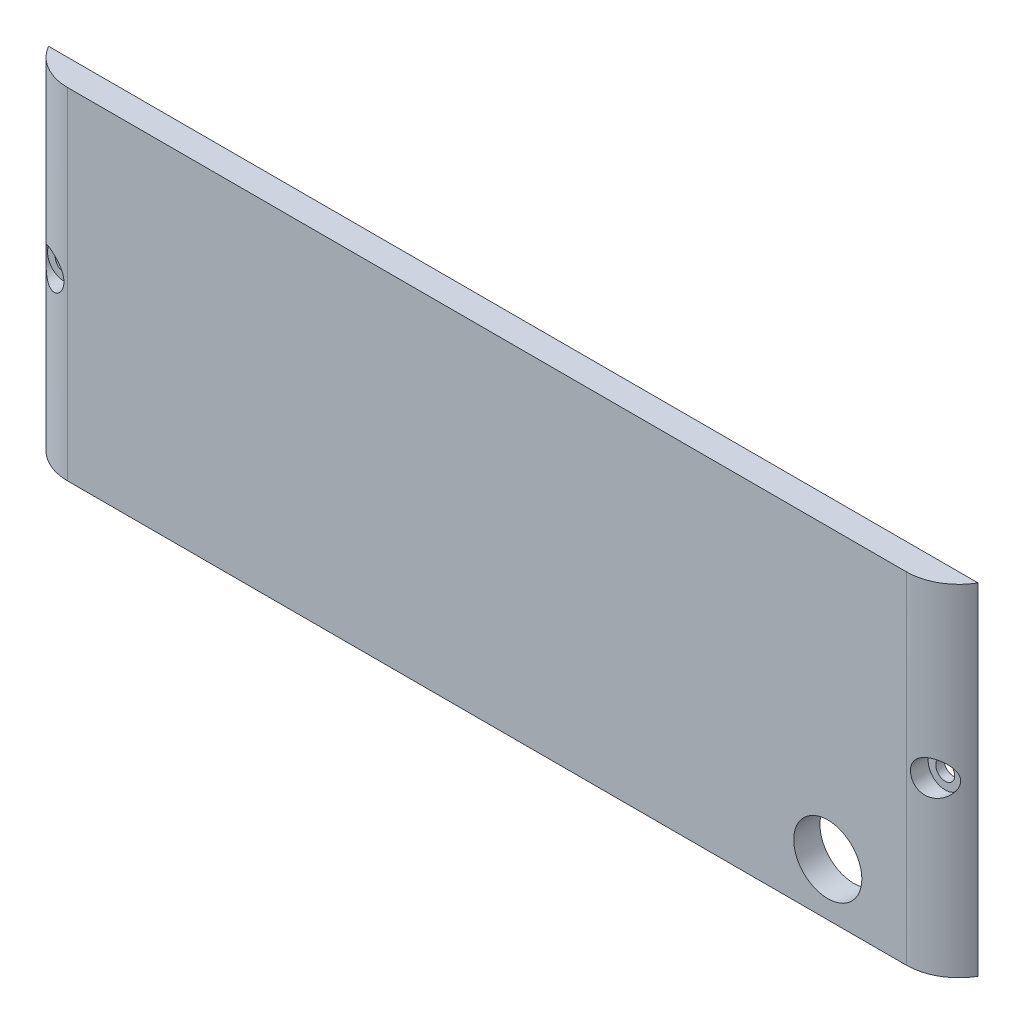
from build123d import *

# Parameters (mm, degrees)
SKIZZE1_W                                            = 180
SKIZZE1_H                                            = 65
AUFSATZ_LINEAR_AUSTRAGEN1_DEPTH                      = 5
STIRNSENKUNG_F_R_M3_ZYLINDERSCHRAUBE_MIT_D           = 3.6
STIRNSENKUNG_F_R_M3_ZYLINDERSCHRAUBE_MIT_DEPTH       = 9.1
STIRNSENKUNG_F_R_M3_ZYLINDERSCHRAUBE_MIT_CBORE_D     = 6.5
STIRNSENKUNG_F_R_M3_ZYLINDERSCHRAUBE_MIT_CBORE_DEPTH = 3.4
STIRNSENKUNG_F_R_M3_ZYLINDERSCHRAUBE_MIT_TIP         = 1.081549114
SCHNITT_LINEAR_AUSTRAGEN1_DEPTH                      = 66
SKIZZE7_R                                            = 6.5
SCHNITT_LINEAR_AUSTRAGEN2_DEPTH                      = 6.0000001


with BuildPart() as part:
    # Skizze1 → Aufsatz-Linear austragen1 (new body)
    with BuildSketch(Plane.XY):
        Rectangle(SKIZZE1_W, SKIZZE1_H)
    extrude(amount=AUFSATZ_LINEAR_AUSTRAGEN1_DEPTH)

    # Stirnsenkung für M3 Zylinderschraube mit Innensechskant1
    with Locations(Plane.XY.offset(5)):
        with Locations((-84, 0), (84, 0)):
            CounterBoreHole(STIRNSENKUNG_F_R_M3_ZYLINDERSCHRAUBE_MIT_D / 2, STIRNSENKUNG_F_R_M3_ZYLINDERSCHRAUBE_MIT_CBORE_D / 2, STIRNSENKUNG_F_R_M3_ZYLINDERSCHRAUBE_MIT_CBORE_DEPTH, depth=STIRNSENKUNG_F_R_M3_ZYLINDERSCHRAUBE_MIT_DEPTH)
            with Locations((0, 0, -(STIRNSENKUNG_F_R_M3_ZYLINDERSCHRAUBE_MIT_DEPTH + STIRNSENKUNG_F_R_M3_ZYLINDERSCHRAUBE_MIT_TIP / 2))):  # 118° drill point
                Cone(0, STIRNSENKUNG_F_R_M3_ZYLINDERSCHRAUBE_MIT_D / 2, STIRNSENKUNG_F_R_M3_ZYLINDERSCHRAUBE_MIT_TIP, mode=Mode.SUBTRACT)

    # Skizze6 → Schnitt-Linear austragen1 (cut, through all)
    with BuildSketch(Plane(origin=(0, 32.5, 0), x_dir=(1, 0, 0), z_dir=(0, 1, 0))):
        with BuildLine():
            Line((-90, -5), (-90, 5))
            ThreePointArc((-90, 5), (-87.071067812, -2.071067812), (-80, -5))
            Line((-80, -5), (-90, -5))
        make_face()
        with BuildLine():
            Line((80, -5), (90, -5))
            Line((90, -5), (90, 5))
            ThreePointArc((90, 5), (87.071067812, -2.071067812), (80, -5))
        make_face()
    extrude(amount=-SCHNITT_LINEAR_AUSTRAGEN1_DEPTH, mode=Mode.SUBTRACT)

    # Skizze7 → Schnitt-Linear austragen2 (cut, through all)
    with BuildSketch(Plane.XY.offset(5)):
        with Locations((65, -22.5)):
            Circle(SKIZZE7_R)
    extrude(amount=-SCHNITT_LINEAR_AUSTRAGEN2_DEPTH, mode=Mode.SUBTRACT)


solid = part.part
